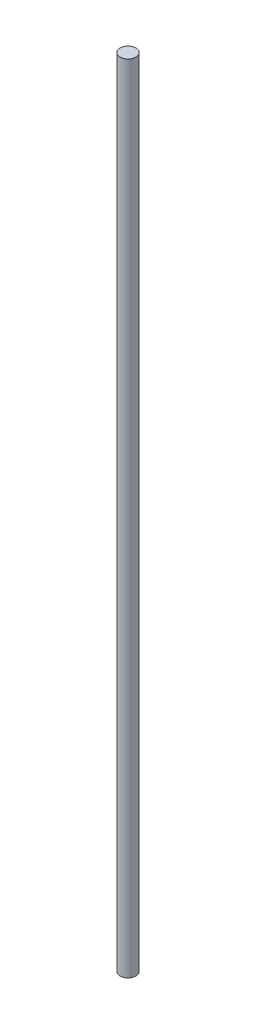
from build123d import *

# Parameters (mm, degrees)
SKETCH2_R           = 4
BOSS_EXTRUDE1_DEPTH = 200


with BuildPart() as part:
    # Sketch2 → Boss-Extrude1 (new body, symmetric)
    with BuildSketch(Plane(origin=(0, 0, 0), x_dir=(1, 0, 0), z_dir=(0, 1, 0))):
        Circle(SKETCH2_R)
    extrude(amount=BOSS_EXTRUDE1_DEPTH, both=True)


solid = part.part
